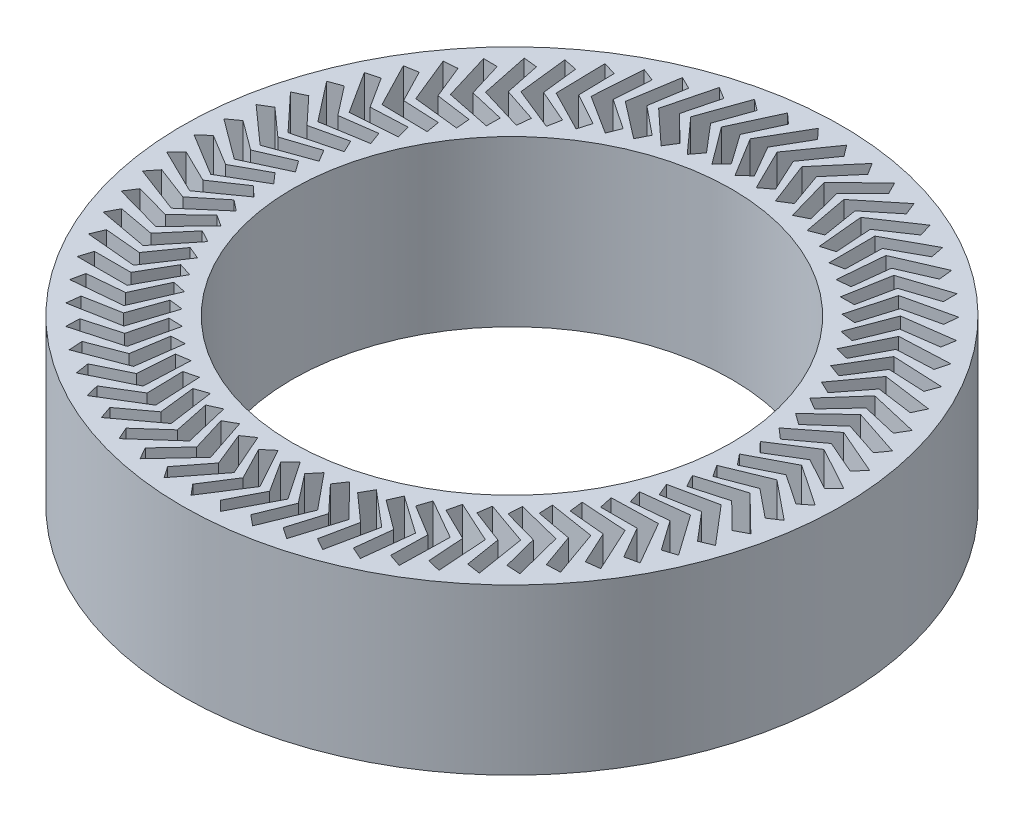
from build123d import *

# Parameters (mm, degrees)
SKETCH1_R           = 152.4
SKETCH1_R_2         = 101.6
BOSS_EXTRUDE1_DEPTH = 76.2
CUT_EXTRUDE2_DEPTH  = 77.2


with BuildPart() as part:
    # Sketch1 → Boss-Extrude1 (new body)
    with BuildSketch(Plane(origin=(0, 0, 0), x_dir=(1, 0, 0), z_dir=(0, 1, 0))):
        Circle(SKETCH1_R)
        Circle(SKETCH1_R_2, mode=Mode.SUBTRACT)
    extrude(amount=BOSS_EXTRUDE1_DEPTH)

    # Sketch2 → Cut-Extrude2 (cut, through all)
    with BuildSketch(Plane(origin=(0, 76.2, 0), x_dir=(1, 0, 0), z_dir=(0, 1, 0))):
        Polygon((0, 141.304106754), (-4.288686807, 145.987018825), (-15.822100939, 126.010559565), (-4.682912072, 107.848378915), (0, 112.137065722), (-8.419799496, 126.720586238), align=None)
        Polygon((3.138404121, 126.961216202), (10.197168631, 111.672464201), (5.143667457, 107.827386063), (-4.297794599, 126.927258544), (9.004391353, 145.772162762), (12.849469491, 140.718661588), align=None)
        Polygon((14.670601932, 126.149805545), (20.309840312, 110.282509471), (14.927624938, 106.912901531), (7.262124619, 126.792198285), (22.222856291, 144.349392649), (25.592464232, 138.967177276), align=None)
        Polygon((26.081234516, 124.293077869), (30.254218259, 107.978719136), (24.587887417, 105.112503026), (18.761867586, 125.60649794), (35.257175643, 141.730498008), (38.123391753, 136.064167166), align=None)
        Polygon((37.275749776, 121.406418606), (39.947900225, 104.780183128), (34.044406917, 102.441109217), (30.10614381, 123.379982594), (47.999342934, 137.937179824), (50.338416845, 132.033686516), align=None)
        Polygon((48.161386434, 117.513747522), (49.31056131, 100.713405523), (43.21882374, 98.920856115), (41.200951044, 120.131101856), (60.343772552, 133.000870727), (62.13632196, 126.909133157), align=None)
        Polygon((58.647942677, 112.647320518), (58.264619553, 95.812084922), (52.035115778, 94.580913645), (51.954354222, 115.886776974), (72.188174667, 126.962474528), (73.419345943, 120.732970752), align=None)
        Polygon((68.648523596, 106.847462338), (66.735878809, 90.11683521), (60.420228459, 89.457243938), (62.277247259, 110.682177761), (83.434402832, 119.87202728), (84.093994103, 113.556376929), align=None)
        Polygon((78.080261228, 100.162232436), (74.654143556, 83.674849021), (68.304680098, 83.592303334), (72.084091412, 104.560431165), (93.989267258, 111.788282661), (94.071812944, 105.438819203), align=None)
        Polygon((86.865001226, 92.647026731), (81.953800558, 76.53950668), (75.623137646, 77.034690579), (81.293624081, 97.572263906), (103.765307015, 102.778225127), (103.270123116, 96.447562214), align=None)
        Polygon((94.929950467, 84.364118584), (88.574362558, 68.769933882), (82.314958059, 69.838744116), (89.829532179, 89.77558214), (112.681514758, 92.91651485), (111.612704524, 86.657110351), align=None)
        Polygon((102.20828024, 75.382142781), (94.460969495, 60.430511753), (88.324690806, 62.064091825), (97.621084482, 81.234991626), (120.664007983, 82.284869068), (119.030427911, 76.148590379), align=None)
        Polygon((108.639680015, 65.775526803), (99.56484309, 51.590343372), (93.602537348, 53.775156922), (104.603717735, 72.021262388), (127.646641236, 70.971384947), (125.461827686, 65.009079205), align=None)
        Polygon((114.170857187, 55.623874094), (103.843691037, 42.322681159), (98.104763787, 45.040624133), (110.719571639, 62.210742288), (133.571554219, 59.069809578), (130.853611244, 53.330882328), align=None)
        Polygon((118.755978679, 45.011304447), (107.262057457, 32.70431988), (101.794063256, 35.932870548), (115.917968303, 51.884724384), (138.389651237, 46.678763164), (135.161100569, 41.210768963), align=None)
        Polygon((122.357050731, 34.025756955), (109.791616688, 22.814960307), (104.639865058, 26.527365881), (120.155832175, 41.128773314), (142.061008021, 33.900921818), (138.348602447, 28.749170188), align=None)
        Polygon((124.944233726, 22.758261325), (111.411408005, 12.736548788), (106.618587984, 16.902047106), (123.39804698, 30.032016275), (144.555202552, 20.842166756), (140.389704234, 16.049346735), align=None)
        Polygon((126.496089451, 11.302183575), (112.108009308, 2.552598214), (107.713835711, 7.136672646), (125.617746705, 18.686404492), (145.851567149, 7.610706937), (141.267492718, 3.21653334), align=None)
        Polygon((126.999758741, -0.247547628), (111.875648339, -7.652503992), (107.916532672, -2.687838532), (126.796538219, 7.185951275), (145.939359727, -5.683817596), (140.974694267, -9.642933263), align=None)
        Polygon((126.451068032, -11.795227574), (110.716250515, -17.794195141), (107.224999257, -12.490077433), (126.924653684, -4.374046997), (144.817852808, -18.931244227), (139.513735101, -22.422495484), align=None)
        Polygon((124.85456395, -23.245168549), (108.639422969, -27.788437984), (105.644965729, -22.188819619), (126.001031496, -15.897800538), (142.496339553, -32.021800606), (136.896721188, -35.016257846), align=None)
        Polygon((122.22347563, -34.502492737), (105.662374951, -37.552417079), (103.189524744, -31.703698258), (124.033325078, -27.289819896), (138.99405675, -44.847014261), (133.145337929, -47.319864468), align=None)
        Polygon((118.579605097, -45.473918403), (101.809775216, -47.005225019), (99.879022858, -40.955870068), (121.037839467, -38.455707213), (134.340025419, -57.300611431), (128.290670468, -59.23136379), align=None)
        Polygon((113.953146612, -56.068532861), (97.113547621, -56.068532861), (95.740891933, -49.86866864), (117.039396198, -49.302938428), (128.572810329, -69.279397689), (122.372946108, -70.652053377), align=None)
        Polygon((108.382436466, -66.198545797), (91.612606585, -64.667239182), (90.809421825, -58.368239718), (112.071127632, -59.741629969), (121.74020044, -80.684113039), (115.441200976, -81.487297799), align=None)
        Polygon((101.913635318, -75.780016734), (85.352534639, -72.730092392), (85.125476249, -66.38415318), (106.174202407, -69.685283548), (113.89881291, -91.420254418), (107.552873697, -91.647312808), align=None)
        Polygon((94.600345691, -84.733550587), (78.385204711, -80.190281152), (78.736154167, -73.849986641), (99.397484303, -79.051502922), (105.113623945, -101.398858777), (98.773329434, -101.04790932), align=None)
        Polygon((86.503167807, -92.984955554), (70.768350289, -86.985987987), (71.694399515, -80.703875856), (91.79712734, -87.762676646), (95.457430387, -110.537240258), (89.175318256, -109.611191032), align=None)
        Polygon((77.689197431, -100.465857895), (62.56508703, -93.060901531), (64.05856249, -86.889027338), (83.43611047, -95.746621192), (85.010246499, -118.759675354), (78.838372306, -117.266199894), align=None)
        Polygon((68.231469898, -107.114268497), (53.843389755, -98.364683136), (55.891916041, -92.354188975), (74.383715711, -102.937179081), (73.858640935, -125.998030378), (67.848146774, -123.949504092), align=None)
        Polygon((58.208354917, -112.875096535), (44.675529196, -102.853383998), (47.262131574, -97.054074717), (64.714954057, -109.274767084), (62.095019412, -132.192326042), (56.29571013, -129.605723664), align=None)
        Polygon((47.702907175, -117.700605976), (35.137473131, -106.489809328), (38.240718199, -100.949739829), (54.509943913, -114.706869954), (49.816859001, -137.291234459), (44.276789503, -134.187989391), align=None)
        Polygon((36.802178121, -121.550811127), (25.308256899, -109.24382656), (28.902430191, -104.008903605), (43.853247207, -119.188475573), (37.125900408, -141.252504469), (31.890977453, -137.658331177), align=None)
        Polygon((25.596494628, -124.393807976), (15.269328479, -111.09261504), (19.324647543, -106.206216849), (32.833168683, -122.682447947), (24.127304912, -144.043311742), (19.24090672, -139.987992678), align=None)
        Polygon((14.17871052, -126.206038556), (5.103873594, -112.020855126), (9.58673478, -107.523471932), (21.541024183, -125.15983492), (10.928782969, -145.64053077), (6.431399775, -141.157669584), align=None)
        Polygon((2.643437151, -126.972486154), (-5.103873594, -112.020855126), (-0.230616687, -107.949753663), (10.070383973, -126.600108083), (-2.360298312, -146.030926491), (-6.431399775, -141.157669584), align=None)
        Polygon((-8.913740571, -126.686799743), (-15.269328479, -111.09261504), (-10.046057192, -107.481529738), (-1.48370261, -126.99133288), (-15.629821418, -145.211263965), (-19.24090672, -139.987992678), align=None)
        Polygon((-20.397056231, -125.351346611), (-25.308256899, -109.24382656), (-19.778252902, -106.122680008), (-13.025494766, -126.330267498), (-28.769830901, -143.188335174), (-31.890977453, -137.658331177), align=None)
        Polygon((-31.711355459, -122.977192743), (-35.137473131, -106.489809328), (-29.34655978, -103.88446433), (-24.459353571, -124.622389734), (-41.671444505, -139.978902742), (-44.276789503, -134.187989391), align=None)
        Polygon((-42.762884409, -119.584011126), (-44.675529196, -102.853383998), (-38.671691822, -100.785429263), (-35.690534468, -121.8818516), (-54.227755395, -135.609561038), (-56.29571013, -129.605723664), align=None)
        Polygon((-53.460066632, -115.199918732), (-53.843389755, -98.364683136), (-47.676378046, -96.851254388), (-46.625972357, -118.131362058), (-66.334718026, -130.116515802), (-67.848146774, -123.949504092), align=None)
        Polygon((-63.714261905, -109.86124353), (-62.56508703, -93.060901531), (-56.286002786, -92.114539517), (-57.175052755, -113.401998847), (-77.892010292, -123.545284138), (-78.838372306, -117.266199894), align=None)
        Polygon((-73.440500738, -103.612223465), (-70.768350289, -86.985987987), (-64.429223981, -86.614534561), (-67.250362659, -107.732950959), (-88.80386483, -115.95031734), (-89.175318256, -109.611191032), align=None)
        Polygon((-82.558188454, -96.504639885), (-78.385204711, -80.190281152), (-72.038564335, -80.396814294), (-76.768414878, -101.17119391), (-98.979862576, -107.394549696), (-98.773329434, -101.04790932), align=None)
        Polygon((-90.991773019, -88.597388466), (-85.352534639, -72.730092392), (-79.050970457, -73.512900704), (-85.650339834, -93.771100486), (-108.335682009, -97.948876991), (-107.552873697, -91.647312808), align=None)
        Polygon((-98.671371096, -79.955991183), (-91.612606585, -64.667239182), (-85.408335341, -66.019836066), (-93.8225391, -85.593990191), (-116.793797861, -87.691569043), (-115.441200976, -81.487297799), align=None)
        Polygon((-105.533347117, -70.652053377), (-97.113547621, -56.068532861), (-91.057979861, -57.979710275), (-101.217295259, -76.707621137), (-124.284123522, -76.707621137), (-122.372946108, -70.652053377), align=None)
        Polygon((-111.520840587, -60.762670405), (-101.809775216, -47.005225019), (-95.953089283, -49.459146345), (-107.773333032, -67.185628575), (-130.744591793, -65.088049724), (-128.290670468, -59.23136379), align=None)
        Polygon((-116.58423725, -50.36978881), (-105.662374951, -37.552417079), (-100.053101187, -40.528748351), (-113.436327026, -57.106914737), (-136.121669201, -52.929138232), (-133.145337929, -47.319864468), align=None)
        Polygon((-120.681580207, -39.559527282), (-108.639422969, -27.788437984), (-103.324041584, -31.262516385), (-118.159351889, -46.554995018), (-140.370799588, -40.331639231), (-136.896721188, -35.016257846), align=None)
        Polygon((-123.778917583, -28.421463051), (-110.716250515, -17.794195141), (-105.738806433, -21.737233362), (-121.90327115, -35.617305948), (-143.456773321, -27.399939566), (-139.513735101, -22.422495484), align=None)
        Polygon((-125.850583865, -17.047889627), (-111.875648339, -7.652503992), (-107.27738623, -12.031828777), (-124.637061514, -24.384480664), (-145.354019051, -14.241195373), (-140.974694267, -9.642933263), align=None)
        Polygon((-126.879412575, -5.533052021), (-112.108009308, 2.552598214), (-107.927031819, -2.22672467), (-126.338069933, -12.949597893), (-146.046815602, -0.96444415), (-141.267492718, 3.21653334), align=None)
        Polygon((-126.856878513, 6.027634197), (-111.411408005, 12.736548788), (-107.682360032, 7.596830778), (-126.992201316, -1.407410676), (-145.529422243, 12.320298762), (-140.389704234, 16.049346735), align=None)
        Polygon((-125.783168403, 17.53837354), (-109.791616688, 22.814960307), (-106.545398297, 17.357436495), (-126.594035325, 10.146438789), (-143.806126259, 25.502951798), (-138.348602447, 28.749170188), align=None)
        Polygon((-123.667179347, 28.903784396), (-107.262057457, 32.70431988), (-104.525567837, 26.974213026), (-125.146871288, 21.616211667), (-140.891207423, 38.474279343), (-135.161100569, 41.210768963), align=None)
        Polygon((-120.526445095, 40.029689392), (-103.843691037, 42.322681159), (-101.639605602, 36.367472733), (-122.662700862, 32.906865807), (-136.80881967, 51.126796893), (-130.853611244, 53.330882328), align=None)
        Polygon((-116.38699076, 50.823895775), (-99.56484309, 51.590343372), (-97.911425586, 45.459380107), (-119.162108666, 43.924843293), (-131.592790951, 63.355661702), (-125.461827686, 65.009079205), align=None)
        Polygon((-111.283117166, 61.196959351), (-94.460969495, 60.430511753), (-93.371920661, 54.174596741), (-114.674101708, 54.578845695), (-125.286342923, 75.059541545), (-119.030427911, 76.148590379), align=None)
        Polygon((-105.257116616, 71.062925648), (-88.574362558, 68.769933882), (-88.058706595, 62.440905605), (-109.235869029, 64.780590592), (-117.941732801, 86.141454387), (-111.612704524, 86.657110351), align=None)
        Polygon((-98.358922448, 80.340042164), (-81.953800558, 76.53950668), (-82.015810354, 70.18980946), (-102.892473537, 74.445543114), (-109.619820336, 96.50957201), (-103.270123116, 96.447562214), align=None)
        Polygon((-90.645695272, 88.951435788), (-74.654143556, 83.674849021), (-75.293305278, 77.357098448), (-95.696478604, 83.493616419), (-100.389563516, 106.077980925), (-94.071812944, 105.438819203), align=None)
        Polygon((-82.181349317, 96.825749801), (-66.735878809, 90.11683521), (-67.946896162, 83.883382156), (-87.707512511, 91.849835324), (-90.327447157, 114.767394281), (-84.093994103, 113.556376929), align=None)
        Polygon((-73.03602282, 103.897735157), (-58.264619553, 95.812084922), (-60.037457665, 89.714581742), (-78.991774348, 99.444957567), (-79.516849123, 122.505808864), (-73.419345943, 120.732970752), align=None)
        Polygon((-63.285496836, 110.108791158), (-49.31056131, 100.713405523), (-51.630529886, 94.802378049), (-69.621485464, 106.216047572), (-68.047349435, 129.229101734), (-62.13632196, 126.909133157), align=None)
        Polygon((-53.010567294, 115.407451038), (-39.947900225, 104.780183128), (-42.795775276, 99.104611994), (-59.674291026, 112.106997955), (-56.013987978, 134.881561567), (-50.338416845, 132.033686516), align=None)
        Polygon((-42.296375496, 119.749808434), (-30.254218259, 107.978719136), (-33.606401394, 102.585633913), (-49.232616618, 117.068994447), (-43.516476977, 139.416350302), (-38.123391753, 136.064167166), align=None)
        Polygon((-31.231702611, 123.099881202), (-20.309840312, 110.282509471), (-24.138554287, 105.216598961), (-38.382985244, 121.060920382), (-30.658374742, 142.795891251), (-25.592464232, 138.967177276), align=None)
        Polygon((-19.908234002, 125.429909587), (-10.197168631, 111.672464201), (-14.470687516, 106.975706134), (-27.215300366, 124.049697404), (-17.546227558, 144.992180474), (-12.849469491, 140.718661588), align=None)
    extrude(amount=-CUT_EXTRUDE2_DEPTH, mode=Mode.SUBTRACT)


solid = part.part
